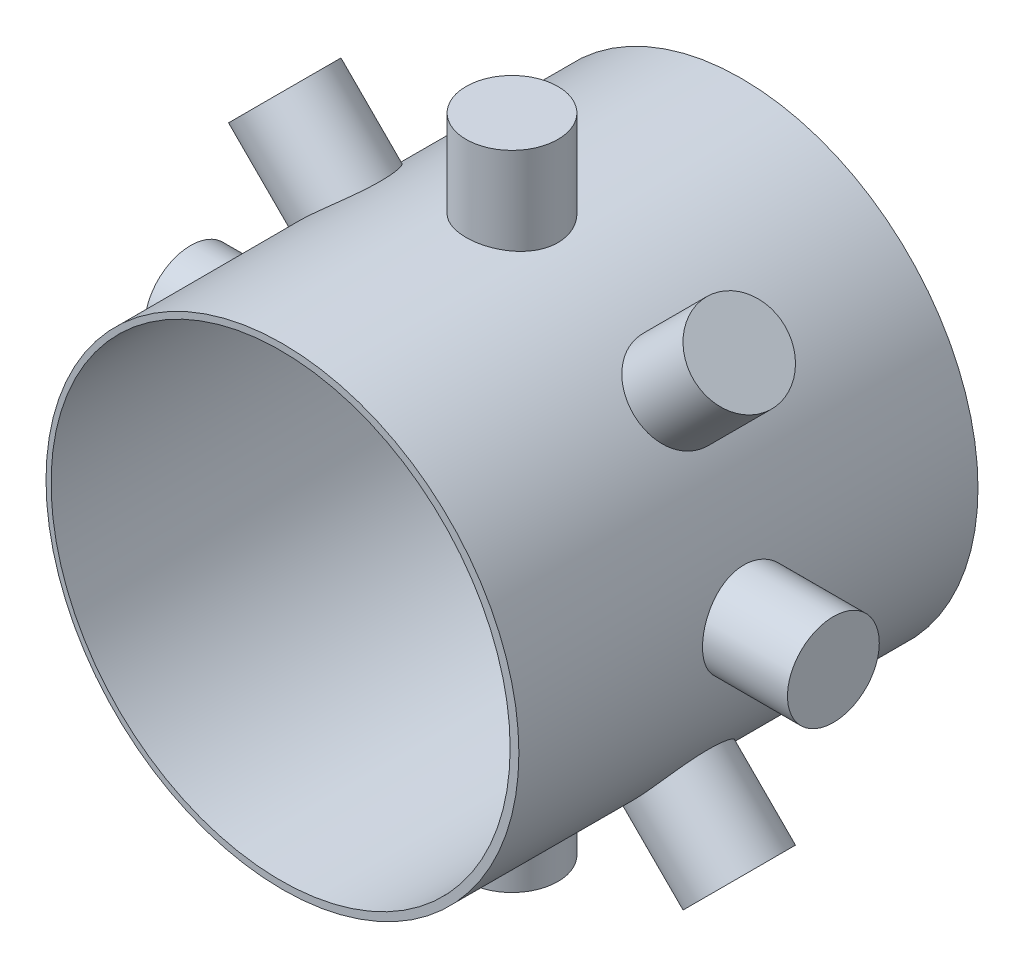
from build123d import *

# Parameters (mm, degrees)
SKETCH1_R           = 0.515
SKETCH1_R_2         = 0.5
BOSS_EXTRUDE1_DEPTH = 0.5
BOSS_EXTRUDE2_START = -0.194802
SKETCH2_R           = 0.1
BOSS_EXTRUDE2_DEPTH = 0.194802
CIRPATTERN1_COUNT   = 8


with BuildPart() as part:
    # Sketch1 → Boss-Extrude1 (new body, symmetric)
    with BuildSketch(Plane.XY):
        Circle(SKETCH1_R)
        with Locations((-0.004, 0)):
            Circle(SKETCH1_R_2, mode=Mode.SUBTRACT)
    extrude(amount=BOSS_EXTRUDE1_DEPTH, both=True)

    # Sketch2 → Boss-Extrude2 (add)
    with BuildSketch(Plane(origin=(0.7, 0, 0), x_dir=(0, 0, -1), z_dir=(1, 0, 0)).offset(BOSS_EXTRUDE2_START)):
        Circle(SKETCH2_R)
    boss_extrude2 = extrude(amount=BOSS_EXTRUDE2_DEPTH)

    # CirPattern1: Boss-Extrude2 ×8 about axis
    cirpattern1_axis = Axis((0, 0, 0.5), (0, 0, -1))
    for i in range(1, CIRPATTERN1_COUNT):
        add(boss_extrude2.rotate(cirpattern1_axis, i * 360 / CIRPATTERN1_COUNT))


solid = part.part
